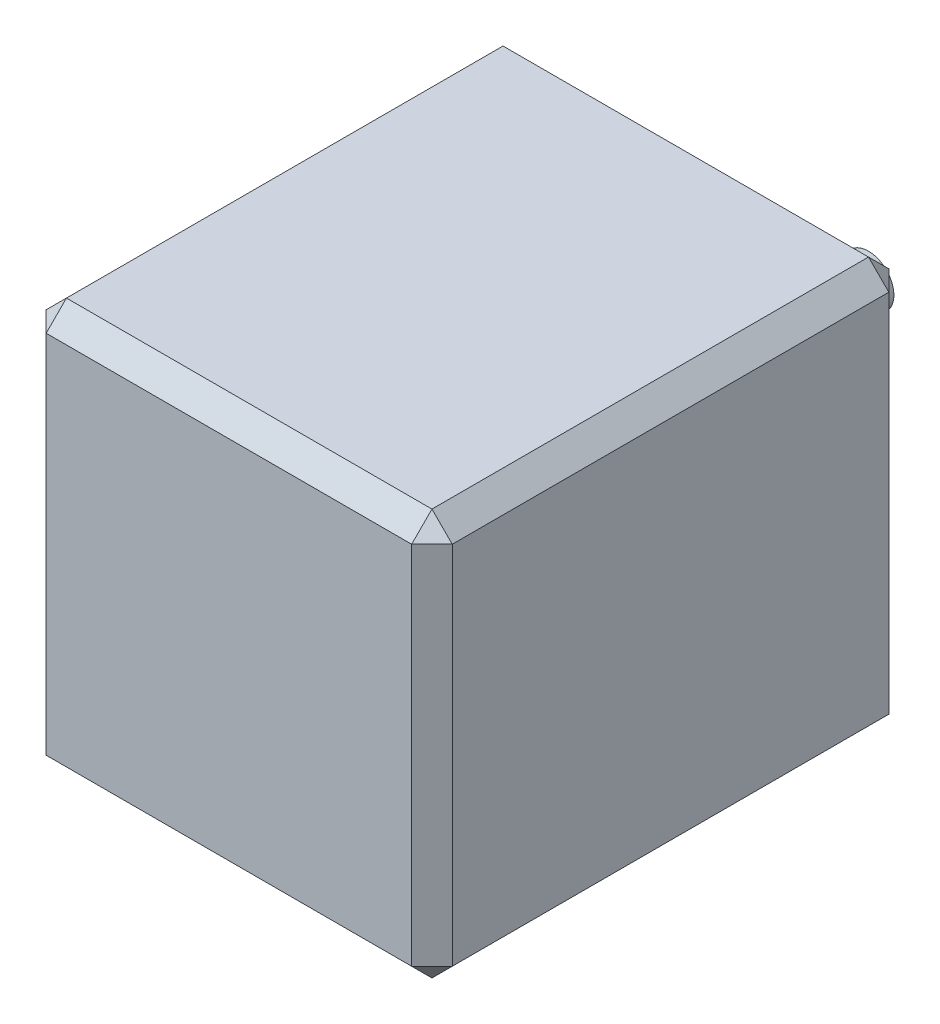
from build123d import *

# Parameters (mm, degrees)
SKETCH1_W           = 40
SKETCH1_H           = 40
BOSS_EXTRUDE1_DEPTH = 23.5
CHAMFER1_SIZE       = 2
SKETCH2_R           = 11
BOSS_EXTRUDE2_DEPTH = 1
SKETCH3_R           = 2.5
BOSS_EXTRUDE3_DEPTH = 15


with BuildPart() as part:
    # Sketch1 → Boss-Extrude1 (new body, symmetric)
    with BuildSketch(Plane.XY):
        Rectangle(SKETCH1_W, SKETCH1_H)
    extrude(amount=BOSS_EXTRUDE1_DEPTH, both=True)

    # Chamfer1
    chamfer1_edges = [part.edges().sort_by_distance(p)[0] for p in [
        (-20, 0, 23.5),
        (0, -20, 23.5),
        (20, 0, 23.5),
        (0, -20, -23.5),
        (-20, 0, -23.5),
        (0, 20, -23.5),
        (20, 0, -23.5),
        (20, -20, 0),
        (-20, -20, 0),
        (-20, 20, 0),
        (20, 20, 0),
        (0, 20, 23.5),
    ]]
    chamfer(chamfer1_edges, length=CHAMFER1_SIZE)

    # Sketch2 → Boss-Extrude2 (add, symmetric)
    with BuildSketch(Plane(origin=(0, 0, -23.5), x_dir=(-1, 0, 0), z_dir=(0, 0, -1))):
        Circle(SKETCH2_R)
    extrude(amount=BOSS_EXTRUDE2_DEPTH, both=True)

    # Sketch3 → Boss-Extrude3 (add, symmetric)
    with BuildSketch(Plane(origin=(0, 0, -24.5), x_dir=(-1, 0, 0), z_dir=(0, 0, -1))):
        Circle(SKETCH3_R)
    extrude(amount=BOSS_EXTRUDE3_DEPTH, both=True)


solid = part.part
